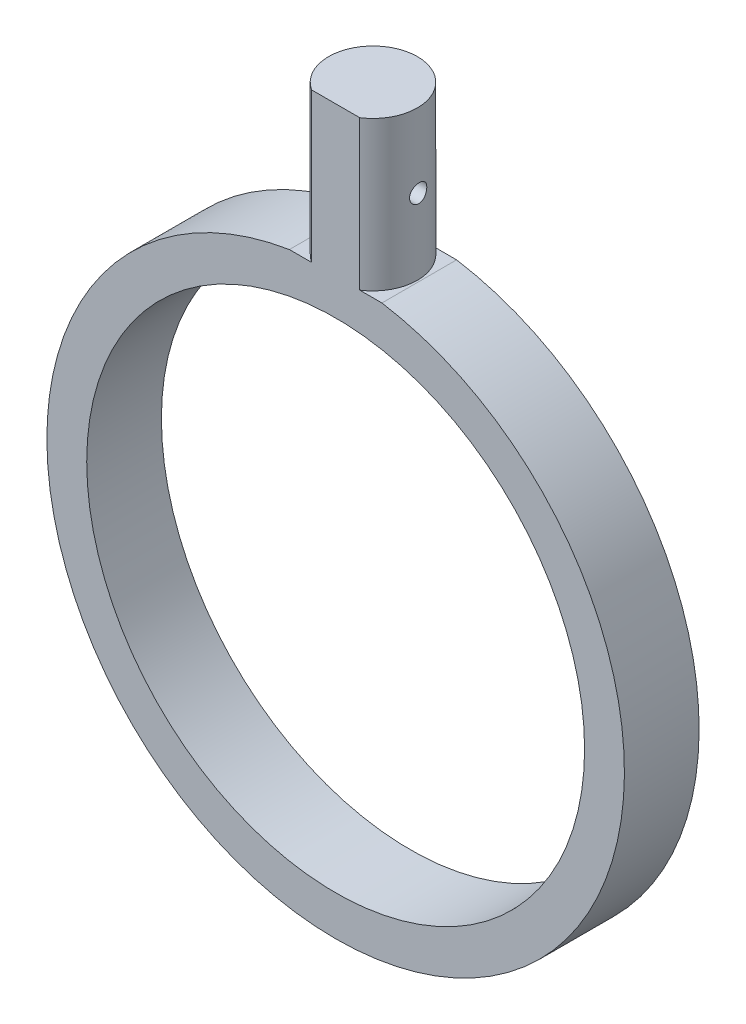
from build123d import *

# Parameters (mm, degrees)
SKETCH1_R           = 31.75
BOSS_EXTRUDE1_DEPTH = 9.525
BOSS_EXTRUDE2_DEPTH = 19.05
SKETCH3_R           = 1.143
CUT_EXTRUDE1_DEPTH  = 43.730618225
SKETCH4_W           = 11.567255286
SKETCH4_H           = 3.936355762
CUT_EXTRUDE2_DEPTH  = 93.234251534


with BuildPart() as part:
    # Sketch1 → Boss-Extrude1 (new body)
    with BuildSketch(Plane.XY):
        with BuildLine():
            Line((-5.900618225, 36.354251534), (5.900618225, 36.354251534))
            ThreePointArc((5.900618225, 36.354251534), (0, -36.83), (-5.900618225, 36.354251534))
        make_face()
        Circle(SKETCH1_R, mode=Mode.SUBTRACT)
    extrude(amount=BOSS_EXTRUDE1_DEPTH)

    # Sketch2 → Boss-Extrude2 (add)
    with BuildSketch(Plane(origin=(0, 36.354251534, 0), x_dir=(1, 0, 0), z_dir=(0, 1, 0))):
        with BuildLine():
            Line((-3.067713808, -9.525), (3.067713808, -9.525))
            ThreePointArc((3.067713808, -9.525), (0, 0.902504348), (-3.067713808, -9.525))
        make_face()
    extrude(amount=BOSS_EXTRUDE2_DEPTH)

    # Sketch3 → Cut-Extrude1 (cut, through all)
    with BuildSketch(Plane(origin=(5.900618225, 0, 0), x_dir=(0, 0, -1), z_dir=(1, 0, 0))):
        with Locations((-4.546893104, 45.879251534)):
            Circle(SKETCH3_R)
    extrude(amount=-CUT_EXTRUDE1_DEPTH, mode=Mode.SUBTRACT)

    # Sketch4 → Cut-Extrude2 (cut, through all)
    with BuildSketch(Plane(origin=(0, 55.404251534, 0), x_dir=(1, 0, 0), z_dir=(0, 1, 0))):
        with Locations((-0.26002139, -11.608026225)):
            Rectangle(SKETCH4_W, SKETCH4_H)
    extrude(amount=-CUT_EXTRUDE2_DEPTH, mode=Mode.SUBTRACT)


solid = part.part
